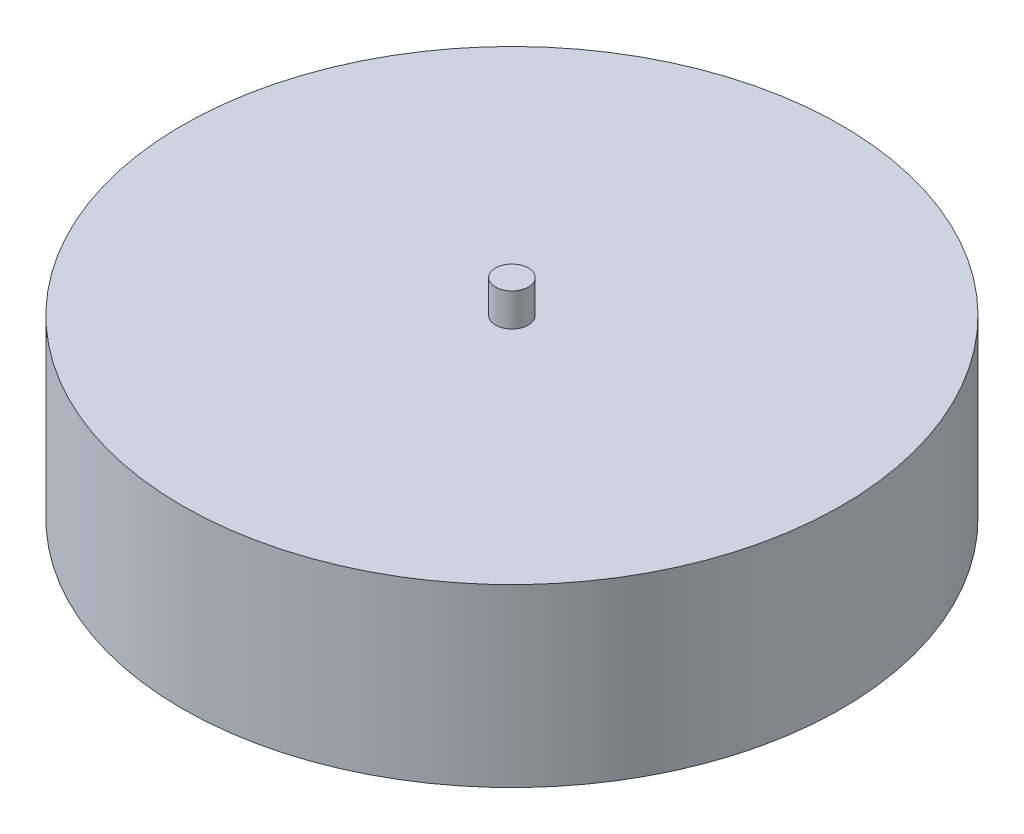
from build123d import *

# Parameters (mm, degrees)
SKETCH1_R           = 60
BOSS_EXTRUDE1_DEPTH = 32
SKETCH2_R           = 3
BOSS_EXTRUDE2_DEPTH = 6


with BuildPart() as part:
    # Sketch1 → Boss-Extrude1 (new body)
    with BuildSketch(Plane(origin=(0, 0, 0), x_dir=(1, 0, 0), z_dir=(0, 1, 0))):
        Circle(SKETCH1_R)
    extrude(amount=BOSS_EXTRUDE1_DEPTH)

    # Sketch2 → Boss-Extrude2 (add)
    with BuildSketch(Plane(origin=(0, 32, 0), x_dir=(1, 0, 0), z_dir=(0, 1, 0))):
        Circle(SKETCH2_R)
    extrude(amount=BOSS_EXTRUDE2_DEPTH)


solid = part.part
